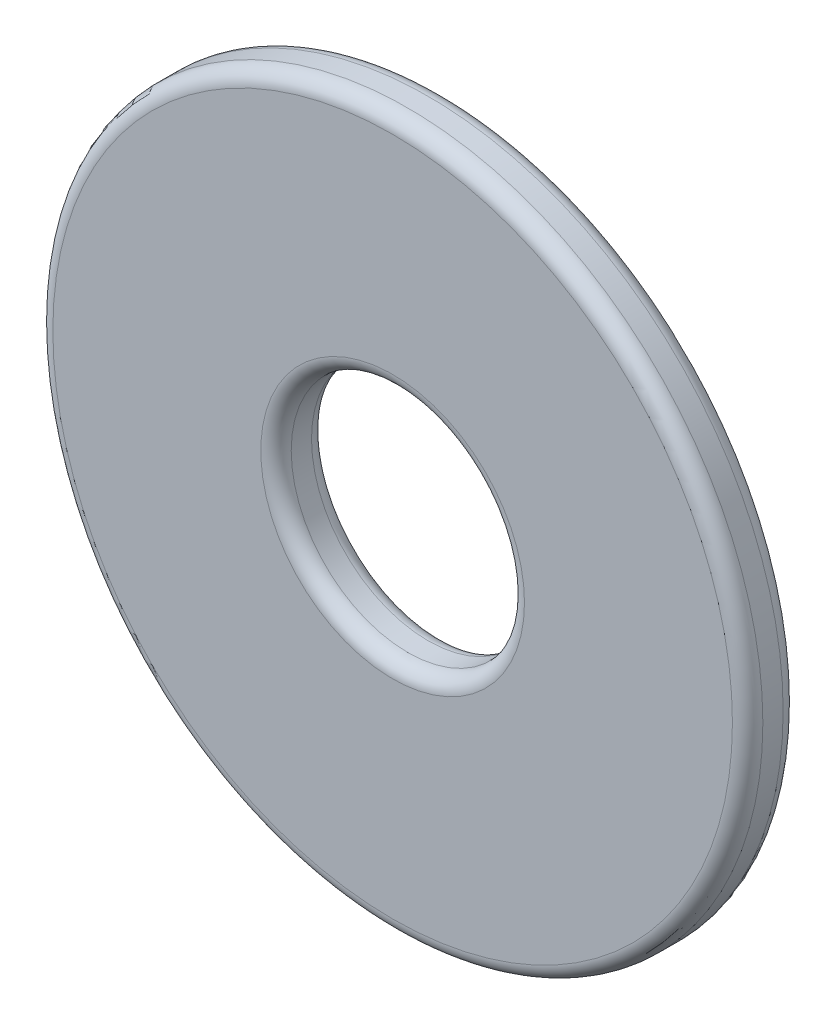
from build123d import *

# Parameters (mm, degrees)
SKETCH1_R      = 3.5
SKETCH1_R_2    = 1.15
EXTRUDE1_DEPTH = 0.25
FILLET1_R      = 0.15


with BuildPart() as part:
    # Sketch1 → Extrude1 (new body, symmetric)
    with BuildSketch(Plane.XY):
        Circle(SKETCH1_R)
        Circle(SKETCH1_R_2, mode=Mode.SUBTRACT)
    extrude(amount=EXTRUDE1_DEPTH, both=True)

    # Fillet1
    fillet1_edges = [part.edges().sort_by_distance(p)[0] for p in [
        (-3.5, 0, -0.25),
        (-3.5, 0, 0.25),
        (-1.15, 0, -0.25),
        (-1.15, 0, 0.25),
    ]]
    fillet(fillet1_edges, radius=FILLET1_R)


solid = part.part
